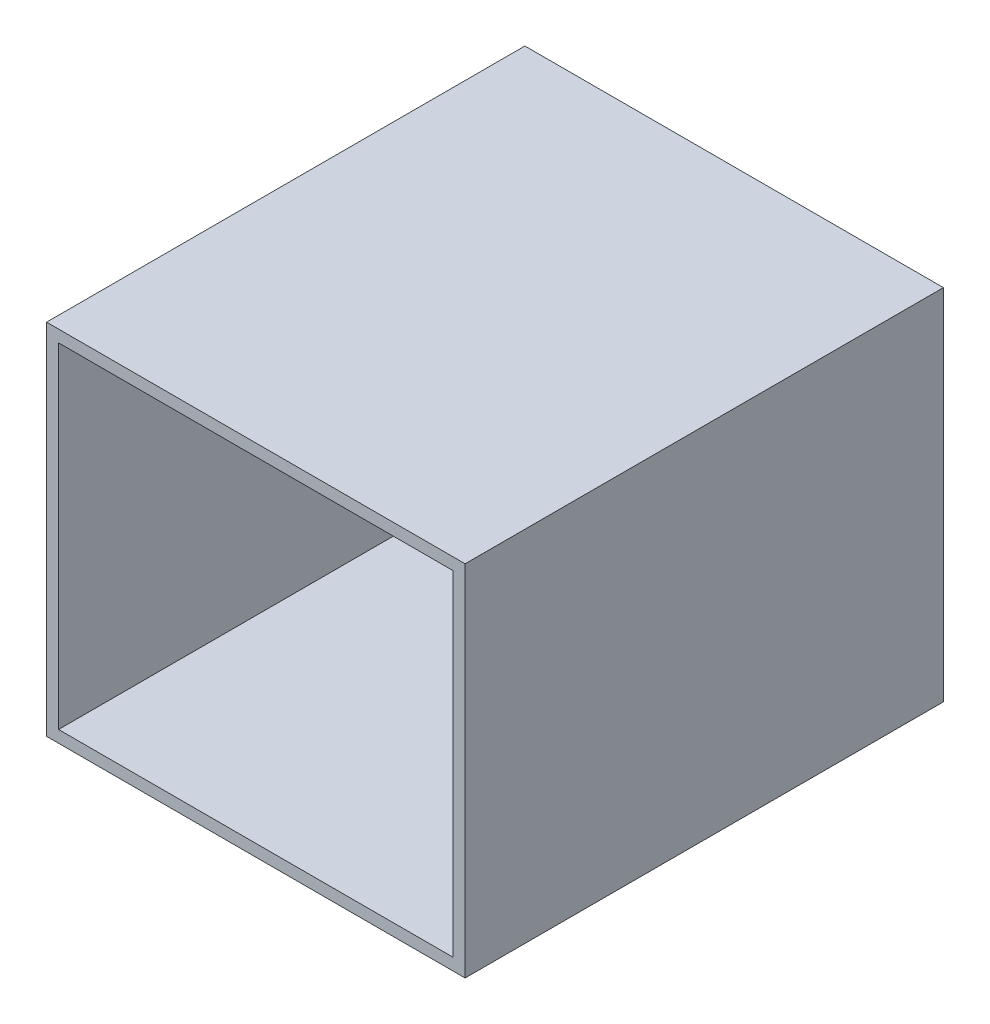
from build123d import *

# Parameters (mm, degrees)
SKETCH1_W           = 350
SKETCH1_H           = 300
SKETCH1_R           = 60
BOSS_EXTRUDE1_DEPTH = 10
SKETCH2_W           = 400
SKETCH2_H           = 300
BOSS_EXTRUDE2_DEPTH = 10
SKETCH3_W           = 350
SKETCH3_H           = 400
BOSS_EXTRUDE3_DEPTH = 10


with BuildPart() as part:
    # Sketch1 → Boss-Extrude1 (new body)
    with BuildSketch(Plane.XY):
        Rectangle(SKETCH1_W, SKETCH1_H)
        with Locations((0, -2.864034897)):
            Circle(SKETCH1_R, mode=Mode.SUBTRACT)
    extrude(amount=BOSS_EXTRUDE1_DEPTH)

    # Sketch2 → Boss-Extrude2 (add)
    with BuildSketch(Plane.ZY.offset(175)):
        with Locations((200, 0)):
            Rectangle(SKETCH2_W, SKETCH2_H)
    boss_extrude2 = extrude(amount=-BOSS_EXTRUDE2_DEPTH)

    # Mirror1: Boss-Extrude2 across plane
    add(boss_extrude2.mirror(Plane(origin=(0, 0, 0), x_dir=(0, 0, 1), z_dir=(1, 0, 0))))

    # Sketch3 → Boss-Extrude3 (add)
    with BuildSketch(Plane.XZ.offset(150)):
        with Locations((0, 200)):
            Rectangle(SKETCH3_W, SKETCH3_H)
    boss_extrude3 = extrude(amount=-BOSS_EXTRUDE3_DEPTH)

    # Mirror2: Boss-Extrude3 across plane
    add(boss_extrude3.mirror(Plane.ZX))


solid = part.part
